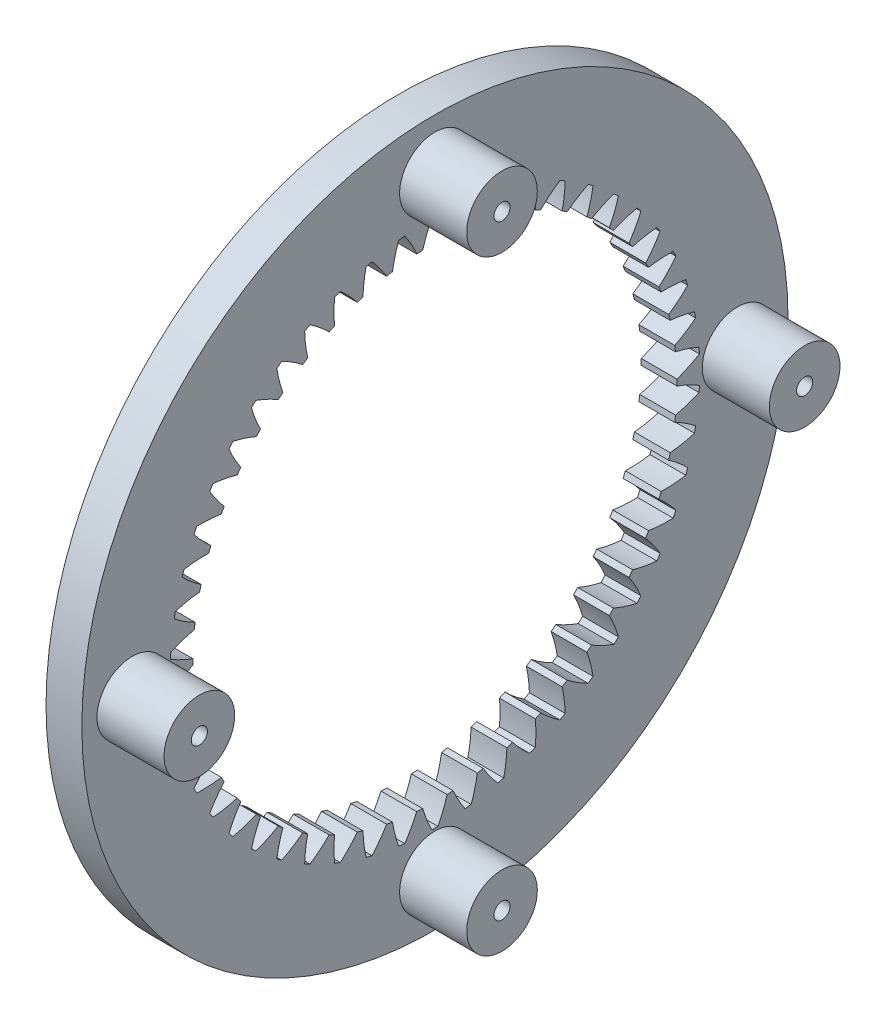
from build123d import *

# Parameters (mm, degrees)
BASPROSKE_W         = 15.2
BASPROSKE_H         = 22
TOOTHCUT_DEPTH      = 101.155079751
TEETHCUTS_COUNT     = 50
TEETHCUTS_ANGLE     = 352.8
SKETCH1_R           = 1.6
CUT_EXTRUDE1_DEPTH  = 16
CUT_EXTRUDE11_DEPTH = 3
SKETCH12_R          = 70
CUT_EXTRUDE12_DEPTH = 8.1
BOSS_EXTRUDE1_START = 13.3
SKETCH13_R          = 7
SKETCH13_R_2        = 1.6
BOSS_EXTRUDE1_DEPTH = 13.3
CUT_EXTRUDE13_START = -4.4
SKETCH14_R          = 1.6
CUT_EXTRUDE13_DEPTH = 4.4


with BuildPart() as part:
    # BasProSke → Base-Revolve (revolve)
    with BuildSketch(Plane(origin=(0, 0, 0), x_dir=(1, 0, 0), z_dir=(0, 1, 0))):
        with Locations((7.6, 59)):
            Rectangle(BASPROSKE_W, BASPROSKE_H)
    revolve(axis=Axis((-10, 0, 0), (1, 0, 0)))

    # TooCutSke → ToothCut (cut, through all)
    with BuildSketch(Plane(origin=(0, 0, 0), x_dir=(0, 0, -1), z_dir=(1, 0, 0))):
        with BuildLine():
            ThreePointArc((2.426707814, 47.913185391), (1.628356337, 50.250450788), (0.603274723, 52.497533853))
            ThreePointArc((0.603274723, 52.497533853), (0, 52.501), (-0.603274723, 52.497533853))
            ThreePointArc((-0.603274723, 52.497533853), (-1.628356337, 50.250450788), (-2.426707814, 47.913185391))
            ThreePointArc((-2.426707814, 47.913185391), (0, 47.9746), (2.426707814, 47.913185391))
        make_face()
    toothcut = extrude(amount=TOOTHCUT_DEPTH, mode=Mode.SUBTRACT)

    # TeethCuts: ToothCut ×50 about axis
    teethcuts_axis = Axis((-10, 0, 0), (1, 0, 0))
    for i in range(1, TEETHCUTS_COUNT):
        add(toothcut.rotate(teethcuts_axis, i * TEETHCUTS_ANGLE / (TEETHCUTS_COUNT - 1)), mode=Mode.SUBTRACT)

    # Sketch1 → Cut-Extrude1 (cut)
    with BuildSketch(Plane(origin=(15.2, 0, 0), x_dir=(0, 0, -1), z_dir=(1, 0, 0))):
        with Locations((60, 0)):
            Circle(SKETCH1_R)
        with Locations((0, 60)):
            Circle(SKETCH1_R)
        with Locations((0, -60)):
            Circle(SKETCH1_R)
        with Locations((-60, 0)):
            Circle(SKETCH1_R)
    extrude(amount=-CUT_EXTRUDE1_DEPTH, mode=Mode.SUBTRACT)

    # Sketch11 → Cut-Extrude11 (cut)
    with BuildSketch(Plane.ZY):
        Polygon((63.233161507, 0), (61.616580754, 2.8), (58.383419246, 2.8), (56.766838493, 0), (58.383419246, -2.8), (61.616580754, -2.8), align=None)
        Polygon((0, 63.233161507), (-2.8, 61.616580754), (-2.8, 58.383419246), (0, 56.766838493), (2.8, 58.383419246), (2.8, 61.616580754), align=None)
        Polygon((0, -63.233161507), (2.8, -61.616580754), (2.8, -58.383419246), (0, -56.766838493), (-2.8, -58.383419246), (-2.8, -61.616580754), align=None)
        Polygon((-63.233161507, 0), (-61.616580754, -2.8), (-58.383419246, -2.8), (-56.766838493, 0), (-58.383419246, 2.8), (-61.616580754, 2.8), align=None)
    extrude(amount=-CUT_EXTRUDE11_DEPTH, mode=Mode.SUBTRACT)

    # Sketch12 → Cut-Extrude12 (cut)
    with BuildSketch(Plane(origin=(15.2, 0, 0), x_dir=(0, 0, -1), z_dir=(1, 0, 0))):
        Circle(SKETCH12_R)
    extrude(amount=-CUT_EXTRUDE12_DEPTH, mode=Mode.SUBTRACT)

    # Sketch13 → Boss-Extrude1 (add)
    # profile 1 of 4: a face of its own
    with BuildSketch(Plane(origin=(7.1, 0, 0), x_dir=(0, 0, -1), z_dir=(1, 0, 0)).offset(BOSS_EXTRUDE1_START)):
        with Locations((0, 60)):
            Circle(SKETCH13_R)
        with Locations((0, 60)):
            Circle(SKETCH13_R_2, mode=Mode.SUBTRACT)
    # profile 2 of 4: a face of its own
    with BuildSketch(Plane(origin=(7.1, 0, 0), x_dir=(0, 0, -1), z_dir=(1, 0, 0)).offset(BOSS_EXTRUDE1_START)):
        with Locations((60, 0)):
            Circle(SKETCH13_R)
        with Locations((60, 0)):
            Circle(SKETCH13_R_2, mode=Mode.SUBTRACT)
    # profile 3 of 4: a face of its own
    with BuildSketch(Plane(origin=(7.1, 0, 0), x_dir=(0, 0, -1), z_dir=(1, 0, 0)).offset(BOSS_EXTRUDE1_START)):
        with Locations((0, -60)):
            Circle(SKETCH13_R)
        with Locations((0, -60)):
            Circle(SKETCH13_R_2, mode=Mode.SUBTRACT)
    # profile 4 of 4: a face of its own
    with BuildSketch(Plane(origin=(7.1, 0, 0), x_dir=(0, 0, -1), z_dir=(1, 0, 0)).offset(BOSS_EXTRUDE1_START)):
        with Locations((-60, 0)):
            Circle(SKETCH13_R)
        with Locations((-60, 0)):
            Circle(SKETCH13_R_2, mode=Mode.SUBTRACT)
    extrude(amount=-BOSS_EXTRUDE1_DEPTH)

    # Sketch14 → Cut-Extrude13 (cut)
    # profile 1 of 4: a face of its own
    with BuildSketch(Plane.ZY.offset(-3).offset(CUT_EXTRUDE13_START)):
        Polygon((-2.8, 61.616580754), (-2.8, 58.383419246), (0, 56.766838493), (2.8, 58.383419246), (2.8, 61.616580754), (0, 63.233161507), align=None)
        with Locations((0, 60)):
            Circle(SKETCH14_R, mode=Mode.SUBTRACT)
    # profile 2 of 4: a face of its own
    with BuildSketch(Plane.ZY.offset(-3).offset(CUT_EXTRUDE13_START)):
        Polygon((61.616580754, -2.8), (63.233161507, 0), (61.616580754, 2.8), (58.383419246, 2.8), (56.766838493, 0), (58.383419246, -2.8), align=None)
        with Locations((60, 0)):
            Circle(SKETCH14_R, mode=Mode.SUBTRACT)
    # profile 3 of 4: a face of its own
    with BuildSketch(Plane.ZY.offset(-3).offset(CUT_EXTRUDE13_START)):
        Polygon((-2.8, -61.616580754), (0, -63.233161507), (2.8, -61.616580754), (2.8, -58.383419246), (0, -56.766838493), (-2.8, -58.383419246), align=None)
        with Locations((0, -60)):
            Circle(SKETCH14_R, mode=Mode.SUBTRACT)
    # profile 4 of 4: a face of its own
    with BuildSketch(Plane.ZY.offset(-3).offset(CUT_EXTRUDE13_START)):
        Polygon((-61.616580754, 2.8), (-63.233161507, 0), (-61.616580754, -2.8), (-58.383419246, -2.8), (-56.766838493, 0), (-58.383419246, 2.8), align=None)
        with Locations((-60, 0)):
            Circle(SKETCH14_R, mode=Mode.SUBTRACT)
    extrude(amount=CUT_EXTRUDE13_DEPTH, mode=Mode.SUBTRACT)


solid = part.part
